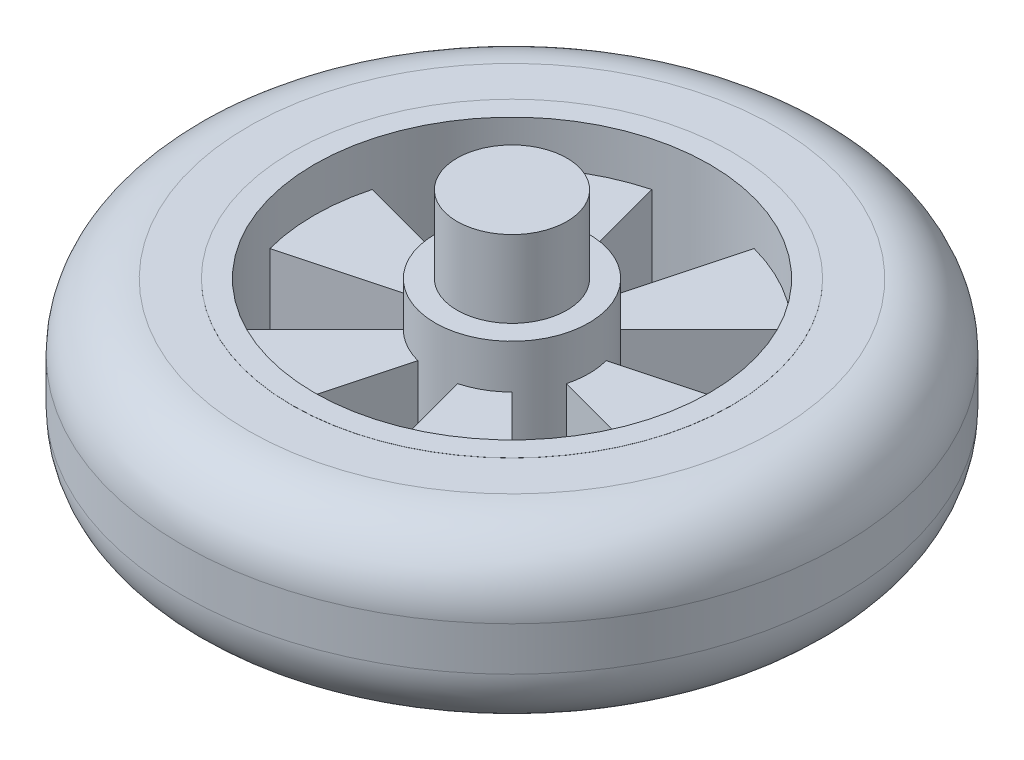
from build123d import *

# Parameters (mm, degrees)
EXTRUDE_1_DEPTH          = 15
EXTRUDE_1_DEPTH_BACK     = 15
SKETCH_1_R               = 5
EXTRUDE_2_DEPTH          = 8
EXTRUDE_2_DEPTH_BACK     = 8
SKETCH_2_R               = 20
SKETCH_4_R               = 18
SKETCH_4_R_2             = 7
CUT_EXTRUDE_1_DEPTH      = 4
CUT_EXTRUDE_2_DEPTH      = 14
PATTERN_CIRCULAR_1_COUNT = 6
EXTRUDE_3_DEPTH          = 7.99
EXTRUDE_3_DEPTH_BACK     = 7.99
SKETCH_6_R               = 30
SKETCH_6_R_2             = 20
FILLET_1_R               = 6


with BuildPart() as part:
    # 草图1 → 凸台-拉伸1 (new, two sides: drawn at the far end of the back side and taken through both)
    with BuildSketch(Plane(origin=(0, 0, 0), x_dir=(1, 0, 0), z_dir=(0, 1, 0)).offset(-EXTRUDE_1_DEPTH_BACK)):
        Circle(SKETCH_1_R)
    extrude(amount=EXTRUDE_1_DEPTH + EXTRUDE_1_DEPTH_BACK)

    # 草图2 → 凸台-拉伸2 (add, two sides: drawn at the far end of the back side and taken through both)
    with BuildSketch(Plane(origin=(0, 0, 0), x_dir=(1, 0, 0), z_dir=(0, 1, 0)).offset(-EXTRUDE_2_DEPTH_BACK)):
        Circle(SKETCH_2_R)
    extrude(amount=EXTRUDE_2_DEPTH + EXTRUDE_2_DEPTH_BACK)

    # 草图4 → 切除-拉伸1 (cut)
    with BuildSketch(Plane(origin=(0, 8, 0), x_dir=(1, 0, 0), z_dir=(0, 1, 0))):
        Circle(SKETCH_4_R)
        Circle(SKETCH_4_R_2, mode=Mode.SUBTRACT)
    cut_extrude_1 = extrude(amount=-CUT_EXTRUDE_1_DEPTH, mode=Mode.SUBTRACT)

    # 镜向1: 切除-拉伸1 across plane
    add(cut_extrude_1.mirror(Plane.ZX), mode=Mode.SUBTRACT)

    # 草图5 → 切除-拉伸2 (cut)
    with BuildSketch(Plane(origin=(0, 4, 0), x_dir=(1, 0, 0), z_dir=(0, 1, 0))):
        with BuildLine():
            Line((-1.811733, 6.761481), (-4.658743, 17.386665))
            ThreePointArc((-4.658743, 17.386665), (0, 18), (4.658743, 17.386665))
            Line((4.658743, 17.386665), (1.811733, 6.761481))
            ThreePointArc((1.811733, 6.761481), (0, 7), (-1.811733, 6.761481))
        make_face()
    cut_extrude_2 = extrude(amount=-CUT_EXTRUDE_2_DEPTH, mode=Mode.SUBTRACT)

    # 阵列(圆周)1: 切除-拉伸2 ×6 about axis
    pattern_circular_1_axis = Axis((0, -15, 0), (0, 1, 0))
    for i in range(1, PATTERN_CIRCULAR_1_COUNT):
        add(cut_extrude_2.rotate(pattern_circular_1_axis, i * 360 / PATTERN_CIRCULAR_1_COUNT), mode=Mode.SUBTRACT)

    # 草图6 → 凸台-拉伸3 (add, two sides: drawn at the far end of the back side and taken through both)
    with BuildSketch(Plane(origin=(0, 0, 0), x_dir=(1, 0, 0), z_dir=(0, 1, 0)).offset(-EXTRUDE_3_DEPTH_BACK)):
        Circle(SKETCH_6_R)
        Circle(SKETCH_6_R_2, mode=Mode.SUBTRACT)
    extrude(amount=EXTRUDE_3_DEPTH + EXTRUDE_3_DEPTH_BACK)

    # 圆角1
    fillet_1_edges = [part.edges().sort_by_distance(p)[0] for p in [
        (-30, 7.99, 0),
        (-30, -7.99, 0),
    ]]
    fillet(fillet_1_edges, radius=FILLET_1_R)


solid = part.part
